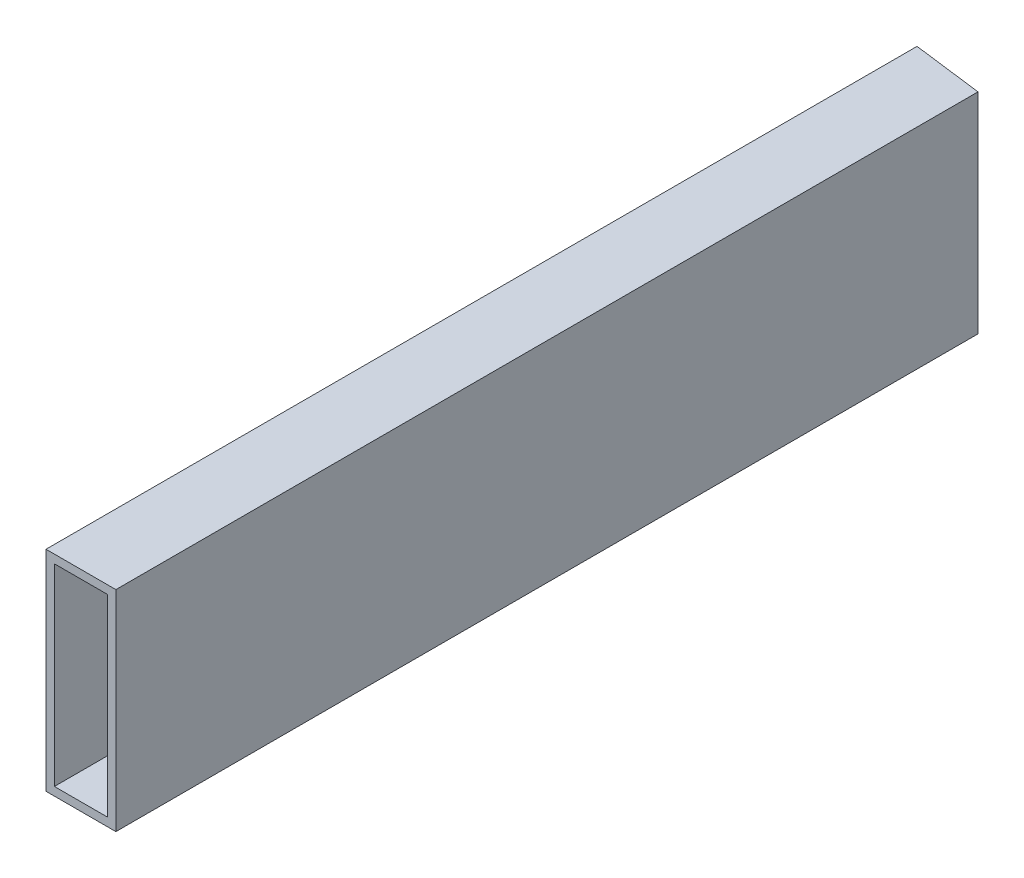
from build123d import *

# Parameters (mm, degrees)
SKETCH2_W               = 9.652
SKETCH2_H               = 3.048
SKETCH2_W_2             = 3.048
SKETCH2_H_2             = 35.052
BOSS_EXTRUDE1_DEPTH     = 315
SKETCH3_W               = 25.4
SKETCH3_H               = 76.2
SKETCH3_W_2             = 19.304
SKETCH3_H_2             = 70.104
BOSS_EXTRUDE2_DEPTH     = 50
CUT_EXTRUDE1_DEPTH      = 1
CUT_EXTRUDE1_DEPTH_BACK = 77.2


with BuildPart() as part:
    # Sketch2 → Boss-Extrude1 (new body)
    with BuildSketch(Plane.XY):
        Polygon((-12.7, 0), (-9.652, 0), (-9.652, 35.052), (-9.652, 38.1), (-12.7, 38.1), align=None)
        with Locations((-4.826, 36.576)):
            Rectangle(SKETCH2_W, SKETCH2_H)
        Polygon((0, 38.1), (0, 35.052), (9.652, 35.052), (9.652, 0), (12.7, 0), (12.7, 38.1), align=None)
        with Locations((11.176, -17.526)):
            Rectangle(SKETCH2_W_2, SKETCH2_H_2)
        Polygon((-9.652, -35.052), (-9.652, 0), (-12.7, 0), (-12.7, -38.1), (0, -38.1), (0, -35.052), align=None)
        Polygon((9.652, -35.052), (0, -35.052), (0, -38.1), (12.7, -38.1), (12.7, -35.052), align=None)
    extrude(amount=BOSS_EXTRUDE1_DEPTH)

    # Sketch3 → Boss-Extrude2 (add)
    with BuildSketch(Plane(origin=(0, 0, 0), x_dir=(-1, 0, 0), z_dir=(0, 0, -1))):
        Rectangle(SKETCH3_W, SKETCH3_H)
        Rectangle(SKETCH3_W_2, SKETCH3_H_2, mode=Mode.SUBTRACT)
    extrude(amount=BOSS_EXTRUDE2_DEPTH)

    # Sketch4 → Cut-Extrude1 (cut, two sides)
    with BuildSketch(Plane(origin=(0, 38.1, 0), x_dir=(1, 0, 0), z_dir=(0, 1, 0))) as cut_extrude1_sk:
        Polygon((12.7, 48.301505629), (115.189557491, -14.672106721), (124.098071564, 55.267937569), (-106.281043419, 84.612151011), (-115.189557491, 14.672106721), (-12.7, 1.617644511), (-12.7, 50), (12.7, 50), align=None)
        Polygon((12.7, -1.617644511), (115.189557491, -14.672106721), (12.7, 48.301505629), align=None)
        Polygon((0, 0), (12.7, -1.617644511), (12.7, 48.301505629), (12.534006261, 48.403498707), align=None)
        Polygon((12.534006261, 48.403498707), (12.7, 48.301505629), (12.7, 50), (-12.7, 50), (-12.7, 1.617644511), (0, 0), align=None)
    extrude(amount=CUT_EXTRUDE1_DEPTH, mode=Mode.SUBTRACT)
    extrude(cut_extrude1_sk.sketch, amount=-CUT_EXTRUDE1_DEPTH_BACK, mode=Mode.SUBTRACT)


solid = part.part
